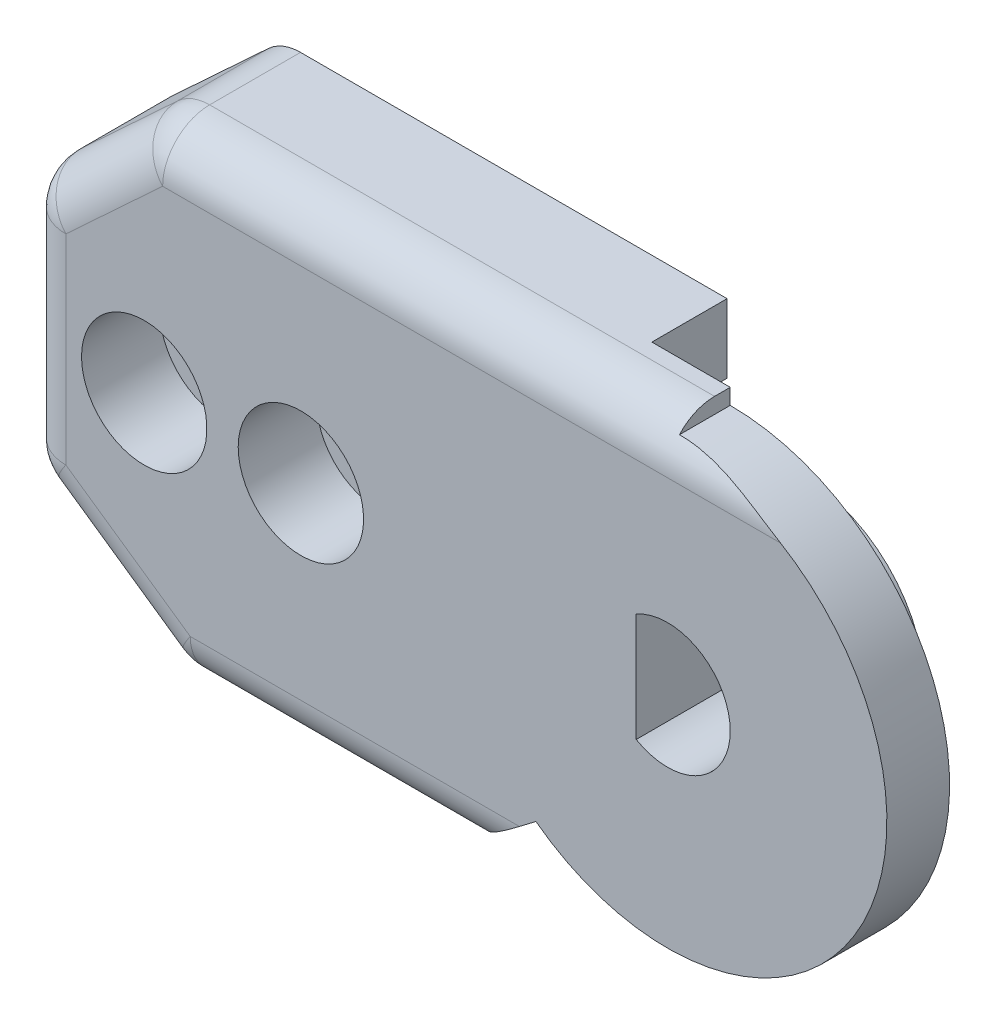
from build123d import *

# Parameters (mm, degrees)
BOSS_EXTRUDE1_DEPTH = 2
BOSS_EXTRUDE2_DEPTH = 6
SKETCH24_R          = 3.9
BOSS_EXTRUDE5_DEPTH = 2.3
SKETCH30_W          = 2.408612022
SKETCH30_H          = 1.324178481
CUT_EXTRUDE12_DEPTH = 8
CUT_EXTRUDE11_DEPTH = 5.3
FILLET1_R           = 1.5
SKETCH34_R          = 0.75
CUT_EXTRUDE13_DEPTH = 8
SKETCH35_R          = 0.75
CUT_EXTRUDE14_DEPTH = 4
SKETCH36_R          = 0.95
CUT_EXTRUDE15_DEPTH = 8
SKETCH37_R          = 2
CUT_EXTRUDE16_DEPTH = 2.5
SKETCH38_W          = 3
SKETCH38_H          = 1.25
CUT_EXTRUDE17_DEPTH = 3.6


with BuildPart() as part:
    # Sketch2 → Boss-Extrude1 (new body)
    with BuildSketch(Plane.XY):
        with BuildLine():
            Line((-2.5, 7.5), (-16.7, 7.5))
            Line((-16.7, 7.5), (-20.7, 3.793442666))
            Line((-20.7, 3.793442666), (-20.7, -4.031648778))
            Line((-20.7, -4.031648778), (-15.7, -7.5))
            Line((-15.7, -7.5), (-6.7, -7.5))
            Line((-6.7, -7.5), (-4.2, -5.6))
            ThreePointArc((-4.2, -5.6), (3.130495168, -6.260990337), (7, 0))
            ThreePointArc((7, 0), (4.949747468, 4.949747468), (0, 7))
            Line((0, 7), (0, 7.5))
            Line((0, 7.5), (-2.5, 7.5))
        make_face()
    extrude(amount=BOSS_EXTRUDE1_DEPTH)

    # Sketch4 → Boss-Extrude2 (add)
    with BuildSketch(Plane.XY.offset(2)):
        Polygon((-15.7, -7.5), (-6.7, -7.5), (-6.759079174, -4.5), (-7.7, -4.5), (-7.7, 2), (-5.5, 2), (-5.5, 5.3), (-2.5, 5.3), (-2.5, 7.5), (-16.7, 7.5), (-20.7, 3.793442666), (-20.7, -4.031648778), align=None)
    extrude(amount=BOSS_EXTRUDE2_DEPTH)

    # Sketch24 → Boss-Extrude5 (add)
    with BuildSketch(Plane.XY.offset(2)):
        Circle(SKETCH24_R)
    extrude(amount=BOSS_EXTRUDE5_DEPTH)

    # Sketch30 → Cut-Extrude12 (cut)
    with BuildSketch(Plane(origin=(-5.5, 0, 0), x_dir=(0, 0, -1), z_dir=(1, 0, 0))):
        with Locations((-3.261593395, 4.63791076)):
            Rectangle(SKETCH30_W, SKETCH30_H)
    extrude(amount=-CUT_EXTRUDE12_DEPTH, mode=Mode.SUBTRACT)

    # Sketch28 → Cut-Extrude11 (cut, through all)
    with BuildSketch(Plane.XY.offset(4.3)):
        with BuildLine():
            Line((-1, 1.732050808), (-1, -1.732050808))
            ThreePointArc((-1, -1.732050808), (2, 0), (-1, 1.732050808))
        make_face()
    extrude(amount=-CUT_EXTRUDE11_DEPTH, mode=Mode.SUBTRACT)

    # Fillet1
    fillet1_edges = [part.edges().sort_by_distance(p)[0] for p in [
        (-11.2, -7.5, 0),
        (-8.35, 7.5, 0),
        (-18.7, 5.646721333, 0),
        (-18.2, -5.765824389, 0),
        (-20.7, -0.119103056, 0),
        (-15.7, -7.5, 4),
        (-20.7, -4.031648778, 4),
        (-20.7, 3.793442666, 4),
        (-16.7, 7.5, 4),
    ]]
    fillet(fillet1_edges, radius=FILLET1_R)

    # Sketch34 → Cut-Extrude13 (cut, along a direction that is not the sketch's normal)
    with BuildSketch(Plane.XZ.offset(-2)):
        with Locations((-7, 8)):
            Circle(SKETCH34_R)
    extrude(amount=-CUT_EXTRUDE13_DEPTH, dir=(0.668583388, -0.743637179, 0), mode=Mode.SUBTRACT)

    # Sketch35 → Cut-Extrude14 (cut, symmetric, along a direction that is not the sketch's normal)
    with BuildSketch(Plane(origin=(0, -4.5, 0), x_dir=(1, 0, 0), z_dir=(0, 1, 0))):
        with Locations((-8.259079174, -8)):
            Circle(SKETCH35_R)
    extrude(amount=CUT_EXTRUDE14_DEPTH, dir=(0.599919418, 0.80006043, 0), both=True, mode=Mode.SUBTRACT)

    # Sketch36 → Cut-Extrude15 (cut)
    with BuildSketch(Plane.XY.offset(8)):
        with Locations((-11.7, 0)):
            Circle(SKETCH36_R)
        with Locations((-16.7, 0)):
            Circle(SKETCH36_R)
    extrude(amount=-CUT_EXTRUDE15_DEPTH, mode=Mode.SUBTRACT)

    # Sketch37 → Cut-Extrude16 (cut)
    with BuildSketch(Plane(origin=(0, 0, 0), x_dir=(-1, 0, 0), z_dir=(0, 0, -1))):
        with Locations((11.7, 0)):
            Circle(SKETCH37_R)
        with Locations((16.7, 0)):
            Circle(SKETCH37_R)
    extrude(amount=-CUT_EXTRUDE16_DEPTH, mode=Mode.SUBTRACT)

    # Sketch38 → Cut-Extrude17 (cut)
    with BuildSketch(Plane.XY.offset(8)):
        with Locations((-4, 5.925)):
            Rectangle(SKETCH38_W, SKETCH38_H)
    extrude(amount=-CUT_EXTRUDE17_DEPTH, mode=Mode.SUBTRACT)


with BuildPart() as body_2:
    # Split2: the piece on the far side of the plane
    add(part.part)
    split(bisect_by=Plane.XY.offset(4.4), keep=Keep.BOTTOM)


with BuildPart() as part_1:
    add(part.part)

    # Split2
    split(bisect_by=Plane.XY.offset(4.4), keep=Keep.TOP)


with BuildPart() as body_3:
    # Mirror2: mirrored copy
    add(body_2.part.mirror(Plane.XY.offset(8)))


solid = body_3.part
